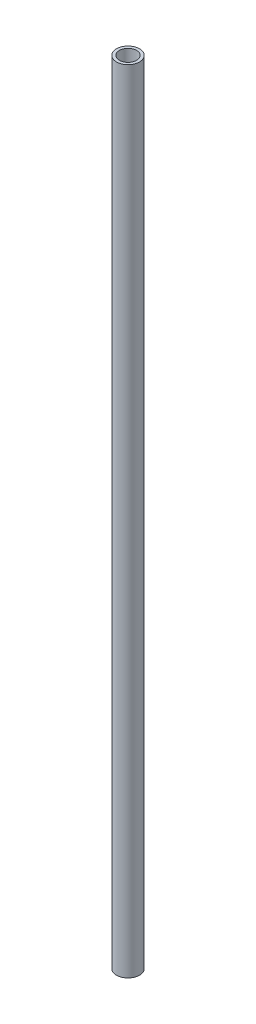
from build123d import *

# Parameters (mm, degrees)
SKETCH1_R           = 12.7
SKETCH1_R_2         = 9.525
BOSS_EXTRUDE1_DEPTH = 438.15


with BuildPart() as part:
    # Sketch1 → Boss-Extrude1 (new body, symmetric)
    with BuildSketch(Plane(origin=(0, 0, 0), x_dir=(1, 0, 0), z_dir=(0, 1, 0))):
        Circle(SKETCH1_R)
        Circle(SKETCH1_R_2, mode=Mode.SUBTRACT)
    extrude(amount=BOSS_EXTRUDE1_DEPTH, both=True)


solid = part.part
